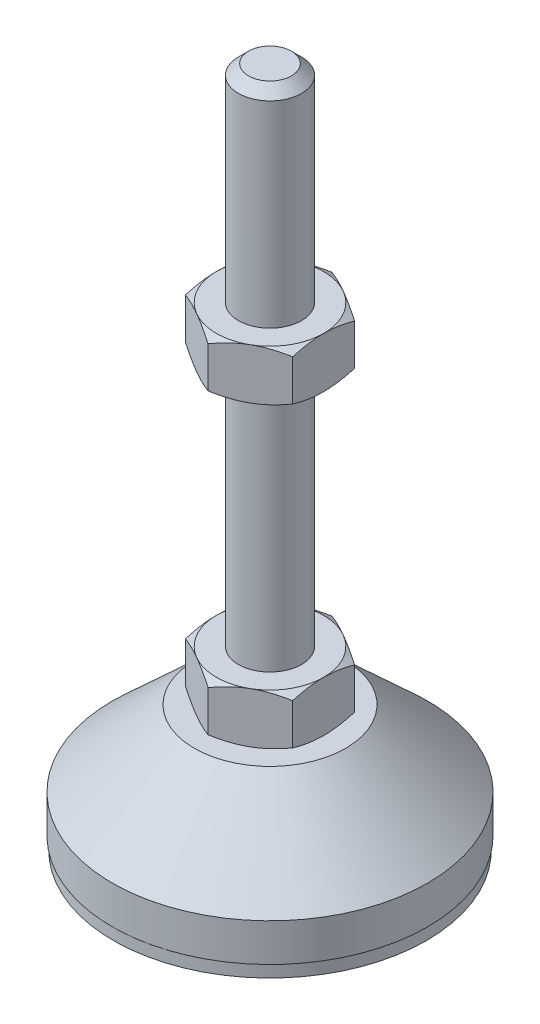
from build123d import *

# Parameters (mm, degrees)
EXTRUDE_1_DEPTH = 8
EXTRUDE_2_DEPTH = 8


with BuildPart() as part:
    # Эскиз1 → Повернуть1 (revolve)
    with BuildSketch(Plane.XY, mode=Mode.PRIVATE) as revolve_1_sk:
        Polygon((0, 0), (-24.8, 0), (-24.8, 2), (-25, 2), (-25, 8), (-12, 20), (-5, 20), (-5, 28), (-5, 106.4), (-3.4, 108), (0, 108), align=None)
    revolve(revolve_1_sk.sketch.rotate(Axis((0, 0, 0), (0, 1, 0)), 180), axis=Axis((0, 0, 0), (0, 1, 0)))  # turned: the seam where the file's is

    # Эскиз2 → Бобышка-Вытянуть1 (add)
    with BuildSketch(Plane(origin=(0, 20, 0), x_dir=(1, 0, 0), z_dir=(0, 1, 0))):
        Polygon((0, 9.814954576), (-8.5, 4.907477288), (-8.5, -4.907477288), (0, -9.814954576), (8.5, -4.907477288), (8.5, 4.907477288), align=None)
    extrude(amount=EXTRUDE_1_DEPTH)

    # Эскиз3 → Бобышка-Вытянуть2 (add)
    with BuildSketch(Plane(origin=(0, 67.2, 0), x_dir=(1, 0, 0), z_dir=(0, 1, 0))):
        Polygon((8.5, 4.907477288), (0, 9.814954576), (-8.5, 4.907477288), (-8.5, -4.907477288), (0, -9.814954576), (8.5, -4.907477288), align=None)
    extrude(amount=EXTRUDE_2_DEPTH)

    # Эскиз4 → Вырез-Повернуть2 (revolve, cut)
    with BuildSketch(Plane.XY, mode=Mode.PRIVATE) as cut_revolve_2_sk:
        Polygon((-15.42820323, 75.2), (-8.5, 75.2), (-15.42820323, 71.2), align=None)
        Polygon((-15.42820323, 67.2), (-15.42820323, 71.2), (-8.5, 67.2), align=None)
        Polygon((-15.42820323, 28), (-15.42820323, 24), (-8.5, 28), align=None)
        Polygon((-15.42820323, 24), (-15.42820323, 20), (-8.5, 20), align=None)
    revolve(cut_revolve_2_sk.sketch.rotate(Axis((0, 108, 0), (0, -1, 0)), 180), axis=Axis((0, 108, 0), (0, -1, 0)), mode=Mode.SUBTRACT)  # turned: the seam where the file's is


solid = part.part
